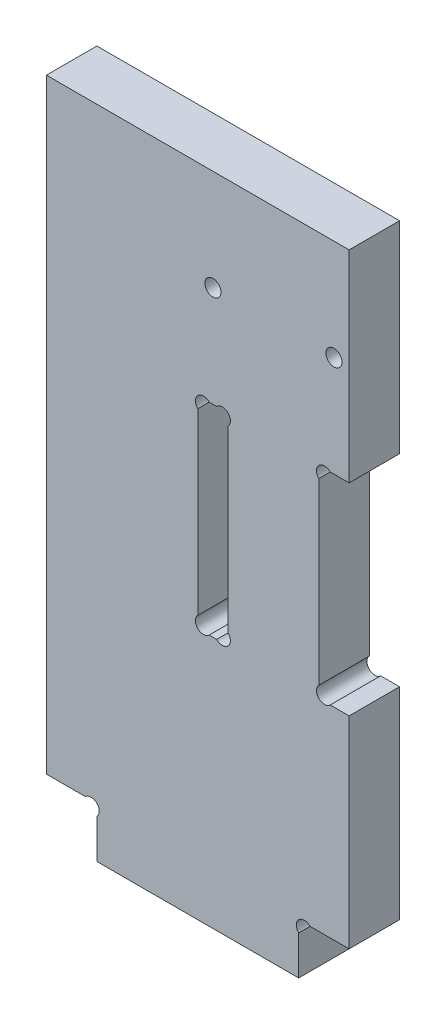
from build123d import *

# Parameters (mm, degrees)
ESQUISSE1_R      = 1.6
EXTRUSION1_DEPTH = 10


with BuildPart() as part:
    # Esquisse1 → Extrusion1 (new body)
    with BuildSketch(Plane.XY):
        with BuildLine():
            Line((326.2627417, 50), (330, 50))
            Line((330, 50), (330, 10))
            Line((330, 10), (322.2627417, 10))
            ThreePointArc((322.2627417, 10), (320, 10), (320, 7.7372583))
            Line((320, 7.7372583), (320, 0))
            Line((320, 0), (280, 0))
            Line((280, 0), (280, 7.7372583))
            ThreePointArc((280, 7.7372583), (280, 10), (277.7372583, 10))
            Line((277.7372583, 10), (270, 10))
            Line((270, 10), (270, 130))
            Line((270, 130), (330, 130))
            Line((330, 130), (330, 90))
            Line((330, 90), (326.2627417, 90))
            ThreePointArc((326.2627417, 90), (324, 90), (324, 87.7372583))
            Line((324, 87.7372583), (324, 52.2627417))
            ThreePointArc((324, 52.2627417), (324, 50), (326.2627417, 50))
        make_face()
        with Locations(Location((327, 110, 0), (0, 0, 180))):  # turned: the seam where the file's is
            Circle(ESQUISSE1_R, mode=Mode.SUBTRACT)
        with Locations((303, 110)):
            Circle(ESQUISSE1_R, mode=Mode.SUBTRACT)
        with BuildLine():
            Line((302.2627417, 50), (303.7372583, 50))
            ThreePointArc((303.7372583, 50), (306, 50), (306, 52.2627417))
            Line((306, 52.2627417), (306, 87.7372583))
            ThreePointArc((306, 87.7372583), (306, 90), (303.7372583, 90))
            Line((303.7372583, 90), (302.2627417, 90))
            ThreePointArc((302.2627417, 90), (300, 90), (300, 87.7372583))
            Line((300, 87.7372583), (300, 52.2627417))
            ThreePointArc((300, 52.2627417), (300, 50), (302.2627417, 50))
        make_face(mode=Mode.SUBTRACT)
    extrude(amount=EXTRUSION1_DEPTH)


solid = part.part
